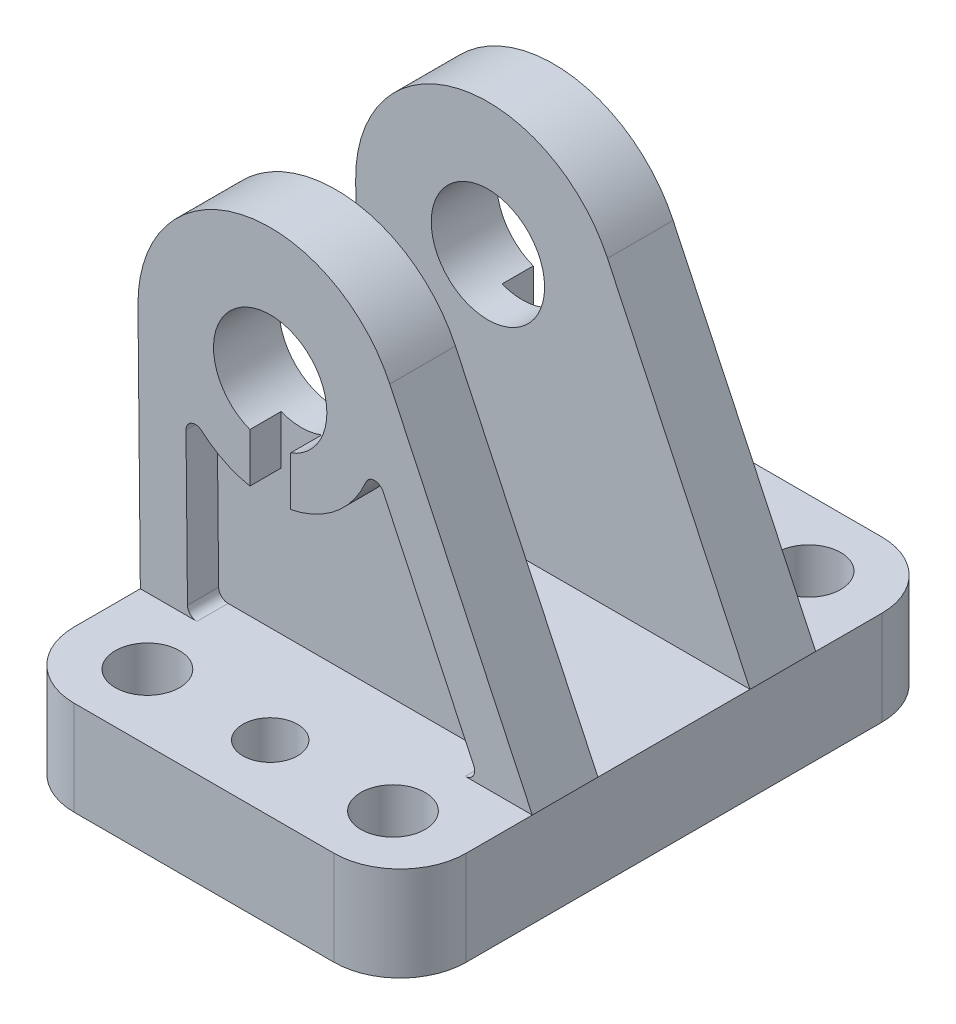
from build123d import *

# Parameters (mm, degrees)
SKETCH1_R               = 3.4
SKETCH1_R_2             = 2.9
BOSS_EXTRUDE1_DEPTH     = 10
CUT_EXTRUDE1_DEPTH      = 5
SKETCH3_R               = 6
BOSS_EXTRUDE2_DEPTH     = 6.95
CUT_EXTRUDE2_DEPTH      = 3.3
SKETCH5_R               = 6
BOSS_EXTRUDE3_DEPTH     = 6.95
CUT_EXTRUDE3_DEPTH      = 3.3
CUT_EXTRUDE4_DEPTH      = 3.3
CUT_EXTRUDE4_DEPTH_BACK = 3.3
CUT_EXTRUDE5_DEPTH      = 3.3
CUT_EXTRUDE5_DEPTH_BACK = 3.3


with BuildPart() as part:
    # Sketch1 → Boss-Extrude1 (new body)
    with BuildSketch(Plane(origin=(0, 0, 0), x_dir=(1, 0, 0), z_dir=(0, 1, 0))):
        with BuildLine():
            Line((-13.75, -29), (13.75, -29))
            ThreePointArc((13.75, -29), (18.699747468, -26.949747468), (20.75, -22))
            Line((20.75, -22), (20.75, 22))
            ThreePointArc((20.75, 22), (18.699747468, 26.949747468), (13.75, 29))
            Line((13.75, 29), (-13.75, 29))
            ThreePointArc((-13.75, 29), (-18.699747468, 26.949747468), (-20.75, 22))
            Line((-20.75, 22), (-20.75, -22))
            ThreePointArc((-20.75, -22), (-18.699747468, -26.949747468), (-13.75, -29))
        make_face()
        with Locations((13, 22)):
            Circle(SKETCH1_R, mode=Mode.SUBTRACT)
        with Locations((13, -22)):
            Circle(SKETCH1_R, mode=Mode.SUBTRACT)
        with Locations((0, 22)):
            Circle(SKETCH1_R_2, mode=Mode.SUBTRACT)
        with Locations((0, -22)):
            Circle(SKETCH1_R_2, mode=Mode.SUBTRACT)
        with Locations((-13, 22)):
            Circle(SKETCH1_R, mode=Mode.SUBTRACT)
        with Locations((-13, -22)):
            Circle(SKETCH1_R, mode=Mode.SUBTRACT)
    extrude(amount=BOSS_EXTRUDE1_DEPTH)

    # Sketch2 → Cut-Extrude1 (cut)
    with BuildSketch(Plane(origin=(0, 0, 0), x_dir=(1, 0, 0), z_dir=(0, 1, 0))):
        with BuildLine():
            Line((-7.121224617, -17), (7.121224617, -17))
            ThreePointArc((7.121224617, -17), (7.499189081, -16.925820104), (7.821078814, -16.714285729))
            ThreePointArc((7.821078814, -16.714285729), (10.936048151, -14.893657568), (14.541666667, -14.762371667))
            ThreePointArc((14.541666667, -14.762371667), (15.37915287, -14.561595372), (15.75, -13.784313784))
            Line((15.75, -13.784313784), (15.75, 13.784313784))
            ThreePointArc((15.75, 13.784313784), (15.379152861, 14.561595378), (14.541666646, 14.762371662))
            ThreePointArc((14.541666646, 14.762371662), (10.936048151, 14.893657568), (7.82107883, 16.714285714))
            ThreePointArc((7.82107883, 16.714285714), (7.49918909, 16.9258201), (7.121224617, 17))
            Line((7.121224617, 17), (-7.121224617, 17))
            ThreePointArc((-7.121224617, 17), (-7.499189081, 16.925820104), (-7.821078814, 16.714285729))
            ThreePointArc((-7.821078814, 16.714285729), (-10.936048151, 14.893657568), (-14.541666667, 14.762371667))
            ThreePointArc((-14.541666667, 14.762371667), (-15.37915287, 14.561595372), (-15.75, 13.784313784))
            Line((-15.75, 13.784313784), (-15.75, -13.784313784))
            ThreePointArc((-15.75, -13.784313784), (-15.379152861, -14.561595378), (-14.541666646, -14.762371662))
            ThreePointArc((-14.541666646, -14.762371662), (-10.936048151, -14.893657568), (-7.82107883, -16.714285714))
            ThreePointArc((-7.82107883, -16.714285714), (-7.49918909, -16.9258201), (-7.121224617, -17))
        make_face()
    extrude(amount=CUT_EXTRUDE1_DEPTH, mode=Mode.SUBTRACT)

    # Sketch3 → Boss-Extrude2 (add)
    with BuildSketch(Plane.XY.offset(15)):
        with BuildLine():
            Line((-20.999349483, 35.865040592), (-20.75, 10))
            Line((-20.75, 10), (20.75, 10))
            Line((20.75, 10), (5.66104691, 41.974771221))
            ThreePointArc((5.66104691, 41.974771221), (-10.127293644, 49.646246168), (-20.999349483, 35.865040592))
        make_face()
        with Locations((-7, 36)):
            Circle(SKETCH3_R, mode=Mode.SUBTRACT)
    extrude(amount=-BOSS_EXTRUDE2_DEPTH)

    # Sketch4 → Cut-Extrude2 (cut)
    with BuildSketch(Plane.XY.offset(15)):
        with BuildLine():
            Line((-15.913359408, 26.969384071), (-15.759315134, 10.990360042))
            ThreePointArc((-15.759315134, 10.990360042), (-15.463051888, 10.289493154), (-14.7593616, 10))
            Line((-14.7593616, 10), (13.643575716, 10))
            ThreePointArc((13.643575716, 10), (14.488196747, 10.464635345), (14.54793621, 11.426769373))
            Line((14.54793621, 11.426769373), (4.956385757, 31.752078197))
            ThreePointArc((4.956385757, 31.752078197), (4.031643534, 32.325101095), (3.131023158, 31.714866422))
            ThreePointArc((3.131023158, 31.714866422), (-4.542840608, 25.277949463), (-14.253955229, 27.73077189))
            ThreePointArc((-14.253955229, 27.73077189), (-15.330435138, 27.887917087), (-15.913359408, 26.969384071))
        make_face()
    extrude(amount=-CUT_EXTRUDE2_DEPTH, mode=Mode.SUBTRACT)

    # Sketch5 → Boss-Extrude3 (add)
    with BuildSketch(Plane.XY.offset(-15)):
        with BuildLine():
            Line((-20.999349483, 35.865040592), (-20.75, 10))
            Line((-20.75, 10), (20.75, 10))
            Line((20.75, 10), (5.66104691, 41.974771221))
            ThreePointArc((5.66104691, 41.974771221), (-10.127293644, 49.646246168), (-20.999349483, 35.865040592))
        make_face()
        with Locations((-7, 36)):
            Circle(SKETCH5_R, mode=Mode.SUBTRACT)
    extrude(amount=BOSS_EXTRUDE3_DEPTH)

    # Sketch6 → Cut-Extrude3 (cut)
    with BuildSketch(Plane.XY.offset(-15)):
        with BuildLine():
            Line((-15.913359408, 26.969384071), (-15.759315134, 10.990360042))
            ThreePointArc((-15.759315134, 10.990360042), (-15.463051888, 10.289493154), (-14.7593616, 10))
            Line((-14.7593616, 10), (13.643575716, 10))
            ThreePointArc((13.643575716, 10), (14.488196747, 10.464635345), (14.54793621, 11.426769373))
            Line((14.54793621, 11.426769373), (4.956385757, 31.752078197))
            ThreePointArc((4.956385757, 31.752078197), (4.031643534, 32.325101095), (3.131023158, 31.714866422))
            ThreePointArc((3.131023158, 31.714866422), (-4.542840608, 25.277949463), (-14.253955229, 27.73077189))
            ThreePointArc((-14.253955229, 27.73077189), (-15.330435138, 27.887917087), (-15.913359408, 26.969384071))
        make_face()
    extrude(amount=CUT_EXTRUDE3_DEPTH, mode=Mode.SUBTRACT)

    # Sketch7 → Cut-Extrude4 (cut, two sides)
    with BuildSketch(Plane.XY.offset(15)) as cut_extrude4_sk:
        with BuildLine():
            Line((-4.85, 23.15), (-4.85, 36))
            Line((-4.85, 36), (-9.15, 36))
            Line((-9.15, 36), (-9.15, 23.15))
            ThreePointArc((-9.15, 23.15), (-7, 21), (-4.85, 23.15))
        make_face()
    extrude(amount=CUT_EXTRUDE4_DEPTH, mode=Mode.SUBTRACT)
    extrude(cut_extrude4_sk.sketch, amount=-CUT_EXTRUDE4_DEPTH_BACK, mode=Mode.SUBTRACT)

    # Sketch8 → Cut-Extrude5 (cut, two sides)
    with BuildSketch(Plane.XY.offset(-15)) as cut_extrude5_sk:
        with BuildLine():
            Line((-4.85, 23.15), (-4.85, 36))
            Line((-4.85, 36), (-9.15, 36))
            Line((-9.15, 36), (-9.15, 23.15))
            ThreePointArc((-9.15, 23.15), (-7, 21), (-4.85, 23.15))
        make_face()
    extrude(amount=CUT_EXTRUDE5_DEPTH, mode=Mode.SUBTRACT)
    extrude(cut_extrude5_sk.sketch, amount=-CUT_EXTRUDE5_DEPTH_BACK, mode=Mode.SUBTRACT)


solid = part.part
